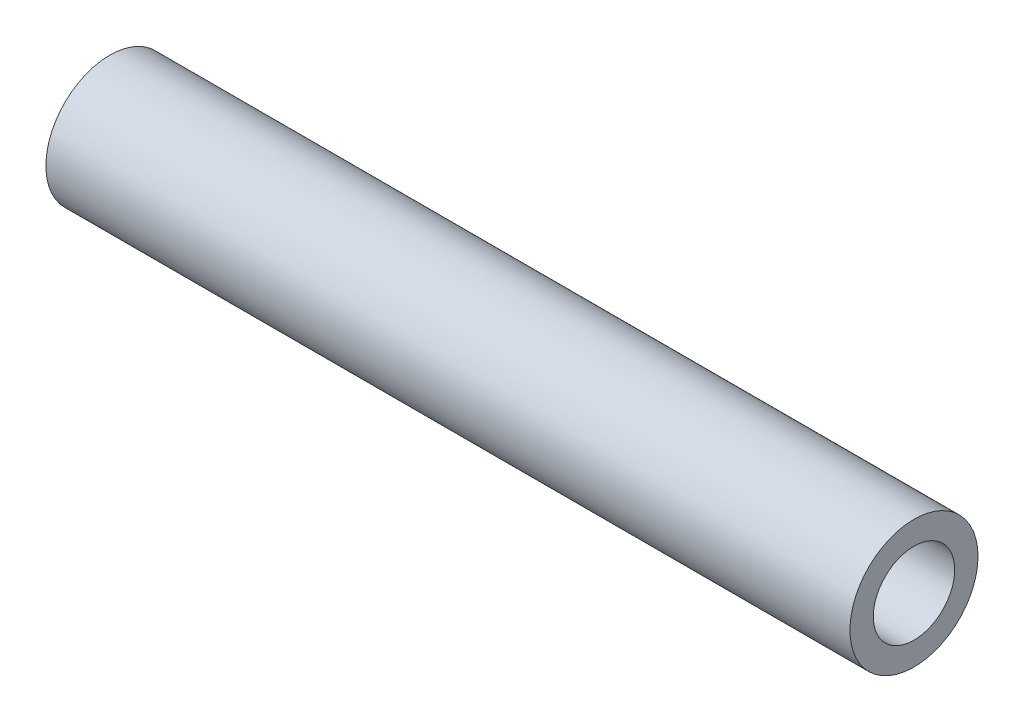
from build123d import *

# Parameters (mm, degrees)
SKETCH1_R              = 3.175
SKETCH1_R_2            = 1.9304
BOSS_EXTRUDE1_DEPTH    = 19.939
F_10_32_TAPPED_HOLE1_D = 4.0386


with BuildPart() as part:
    # Sketch1 → Boss-Extrude1 (new body, symmetric)
    with BuildSketch(Plane(origin=(0, 0, 0), x_dir=(0, 0, -1), z_dir=(1, 0, 0))):
        Circle(SKETCH1_R)
        Circle(SKETCH1_R_2, mode=Mode.SUBTRACT)
    extrude(amount=BOSS_EXTRUDE1_DEPTH, both=True)

    # #10-32 Tapped Hole1 (through all)
    with Locations(Plane(origin=(19.939, 0, 0), x_dir=(0, 0, -1), z_dir=(1, 0, 0))):
        with Locations((0, 0)):
            Hole(F_10_32_TAPPED_HOLE1_D / 2)


solid = part.part
